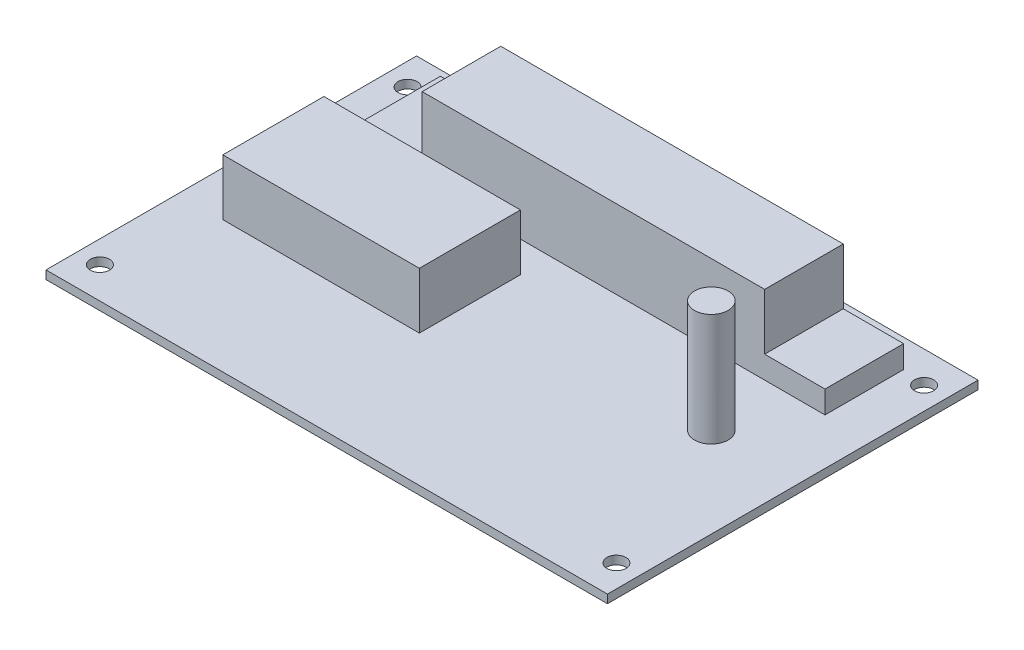
from build123d import *

# Parameters (mm, degrees)
SKIZZE1_W                       = 100
SKIZZE1_H                       = 66
AUFSATZ_LINEAR_AUSTRAGEN1_DEPTH = 1.5
SKIZZE2_W                       = 61
SKIZZE2_H                       = 14
AUFSATZ_LINEAR_AUSTRAGEN2_DEPTH = 14
SKIZZE6_W                       = 82.5
SKIZZE6_H                       = 14
AUFSATZ_LINEAR_AUSTRAGEN4_DEPTH = 4
SKIZZE3_R                       = 3
AUFSATZ_LINEAR_AUSTRAGEN3_DEPTH = 20
DURCHGANGSLOCH_F_R_M31_D        = 3.4
SKIZZE7_W                       = 35
SKIZZE7_H                       = 18
AUFSATZ_LINEAR_AUSTRAGEN5_DEPTH = 10


with BuildPart() as part:
    # Skizze1 → Aufsatz-Linear austragen1 (new body)
    with BuildSketch(Plane(origin=(0, 0, 0), x_dir=(1, 0, 0), z_dir=(0, 1, 0))):
        Rectangle(SKIZZE1_W, SKIZZE1_H)
    extrude(amount=AUFSATZ_LINEAR_AUSTRAGEN1_DEPTH)

    # Skizze2 → Aufsatz-Linear austragen2 (add)
    with BuildSketch(Plane(origin=(0, 1.5, 0), x_dir=(1, 0, 0), z_dir=(0, 1, 0))):
        with Locations((0.5, 21)):
            Rectangle(SKIZZE2_W, SKIZZE2_H)
    extrude(amount=AUFSATZ_LINEAR_AUSTRAGEN2_DEPTH)

    # Skizze6 → Aufsatz-Linear austragen4 (add)
    with BuildSketch(Plane(origin=(0, 1.5, 0), x_dir=(1, 0, 0), z_dir=(0, 1, 0))):
        with Locations((0.5, 21)):
            Rectangle(SKIZZE6_W, SKIZZE6_H)
    extrude(amount=AUFSATZ_LINEAR_AUSTRAGEN4_DEPTH)

    # Skizze3 → Aufsatz-Linear austragen3 (add)
    with BuildSketch(Plane(origin=(0, 1.5, 0), x_dir=(1, 0, 0), z_dir=(0, 1, 0))):
        with Locations((34, 1.5)):
            Circle(SKIZZE3_R)
    extrude(amount=AUFSATZ_LINEAR_AUSTRAGEN3_DEPTH)

    # Durchgangsloch für M31 (through all)
    with Locations(Plane(origin=(0, 1.5, 0), x_dir=(1, 0, 0), z_dir=(0, 1, 0))):
        with Locations((-46, -27.400776428), (-46, 27.400776428), (46, 27.400776428), (46, -27.400776428)):
            Hole(DURCHGANGSLOCH_F_R_M31_D / 2)

    # Skizze7 → Aufsatz-Linear austragen5 (add)
    with BuildSketch(Plane(origin=(0, 1.5, 0), x_dir=(1, 0, 0), z_dir=(0, 1, 0))):
        with Locations((-24.5, -0.5)):
            Rectangle(SKIZZE7_W, SKIZZE7_H)
    extrude(amount=AUFSATZ_LINEAR_AUSTRAGEN5_DEPTH)


solid = part.part
